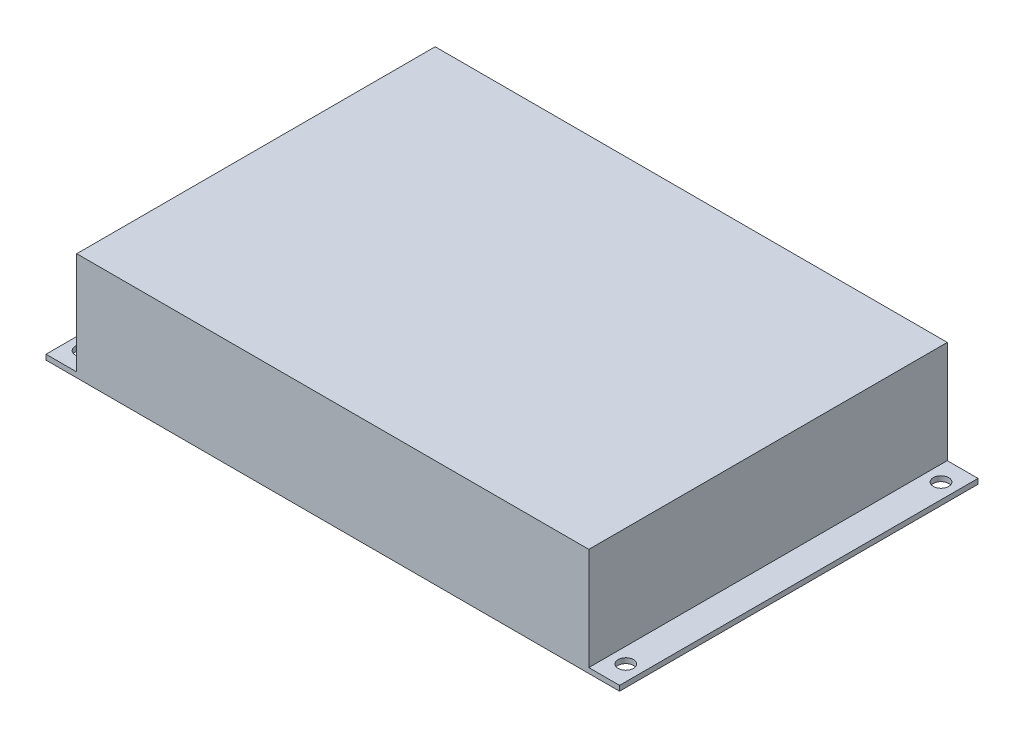
from build123d import *

# Parameters (mm, degrees)
SKETCH_1_W      = 224
SKETCH_1_H      = 140
SKETCH_1_R      = 3
EXTRUDE_1_DEPTH = 2
SKETCH_2_W      = 200
SKETCH_2_H      = 140
EXTRUDE_2_DEPTH = 40


with BuildPart() as part:
    # 草图1 → 凸台-拉伸1 (new body)
    with BuildSketch(Plane(origin=(0, 0, 0), x_dir=(1, 0, 0), z_dir=(0, 1, 0))):
        with Locations((112, 70)):
            Rectangle(SKETCH_1_W, SKETCH_1_H)
        with Locations((6, 131.55)):
            Circle(SKETCH_1_R, mode=Mode.SUBTRACT)
        with Locations((218, 131.55)):
            Circle(SKETCH_1_R, mode=Mode.SUBTRACT)
        with Locations((218, 8.45)):
            Circle(SKETCH_1_R, mode=Mode.SUBTRACT)
        with Locations((6, 8.45)):
            Circle(SKETCH_1_R, mode=Mode.SUBTRACT)
    extrude(amount=EXTRUDE_1_DEPTH)

    # 草图2 → 凸台-拉伸2 (add)
    with BuildSketch(Plane(origin=(0, 2, 0), x_dir=(1, 0, 0), z_dir=(0, 1, 0))):
        with Locations((112, 70)):
            Rectangle(SKETCH_2_W, SKETCH_2_H)
    extrude(amount=EXTRUDE_2_DEPTH)


solid = part.part
